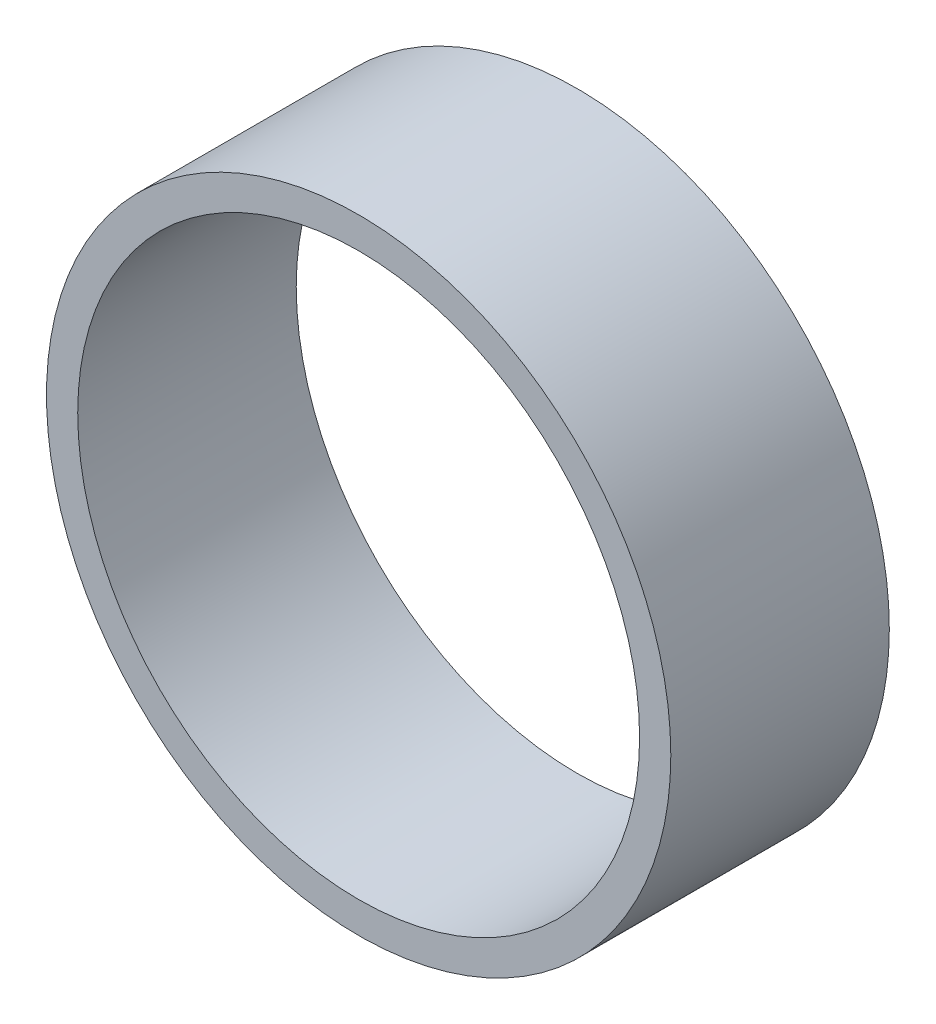
from build123d import *

# Parameters (mm, degrees)
SKETCH_2_R      = 10
SKETCH_2_R_2    = 9
EXTRUDE_1_DEPTH = 7


with BuildPart() as part:
    # 草图2 → 拉伸-薄壁1 (new body)
    with BuildSketch(Plane.XY):
        Circle(SKETCH_2_R)
        Circle(SKETCH_2_R_2, mode=Mode.SUBTRACT)
    extrude(amount=EXTRUDE_1_DEPTH)


solid = part.part
